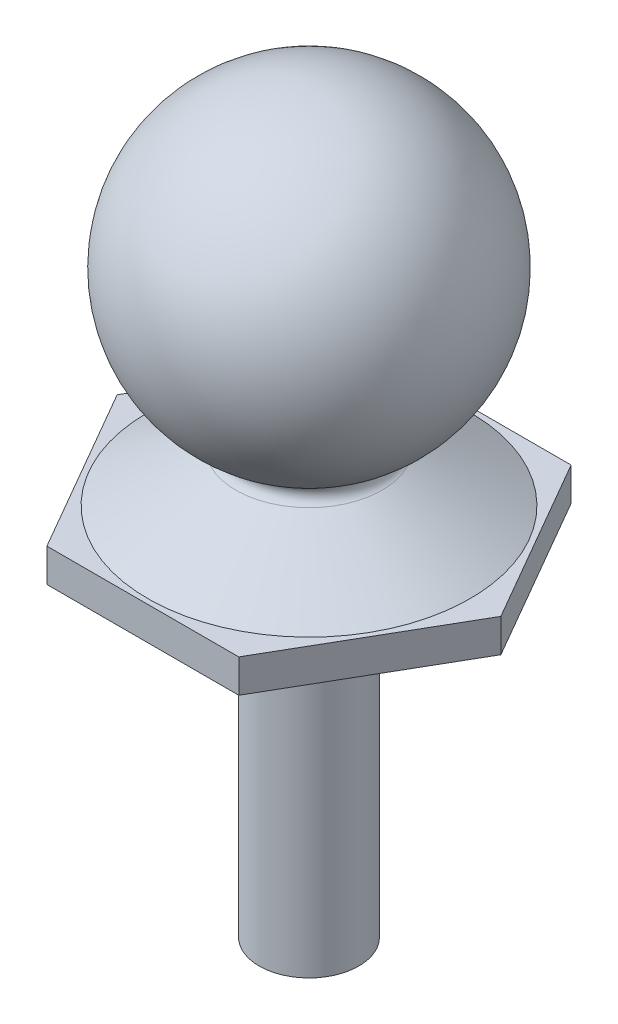
from build123d import *

# Parameters (mm, degrees)
BOSS_EXTRUDE1_DEPTH = 1


with BuildPart() as part:
    # Sketch1 → Revolve1 (revolve)
    with BuildSketch(Plane.XY):
        with BuildLine():
            Line((2.2, -4.709624758), (4.85, -6.209624758))
            Line((4.85, -6.209624758), (5, -6.209624758))
            Line((5, -6.209624758), (5, -7.209624758))
            Line((5, -7.209624758), (1.5, -7.209624758))
            Line((1.5, -7.209624758), (1.5, -17.459624758))
            Line((1.5, -17.459624758), (0, -17.459624758))
            Line((0, -17.459624758), (0, 4.709624758))
            ThreePointArc((0, 4.709624758), (4.57123544, 1.133301337), (2.2, -4.164200447))
            ThreePointArc((2.2, -4.164200447), (2.040995641, -4.436912603), (2.2, -4.709624758))
        make_face()
    revolve(axis=Axis((0, 4.709624758, 0), (0, -1, 0)))

    # Sketch3 → Boss-Extrude1 (add)
    with BuildSketch(Plane.XZ.offset(7.209624758)):
        Polygon((5.773502692, 0), (2.886751346, 5), (-2.886751346, 5), (-5.773502692, 0), (-2.886751346, -5), (2.886751346, -5), align=None)
    extrude(amount=-BOSS_EXTRUDE1_DEPTH)


solid = part.part
